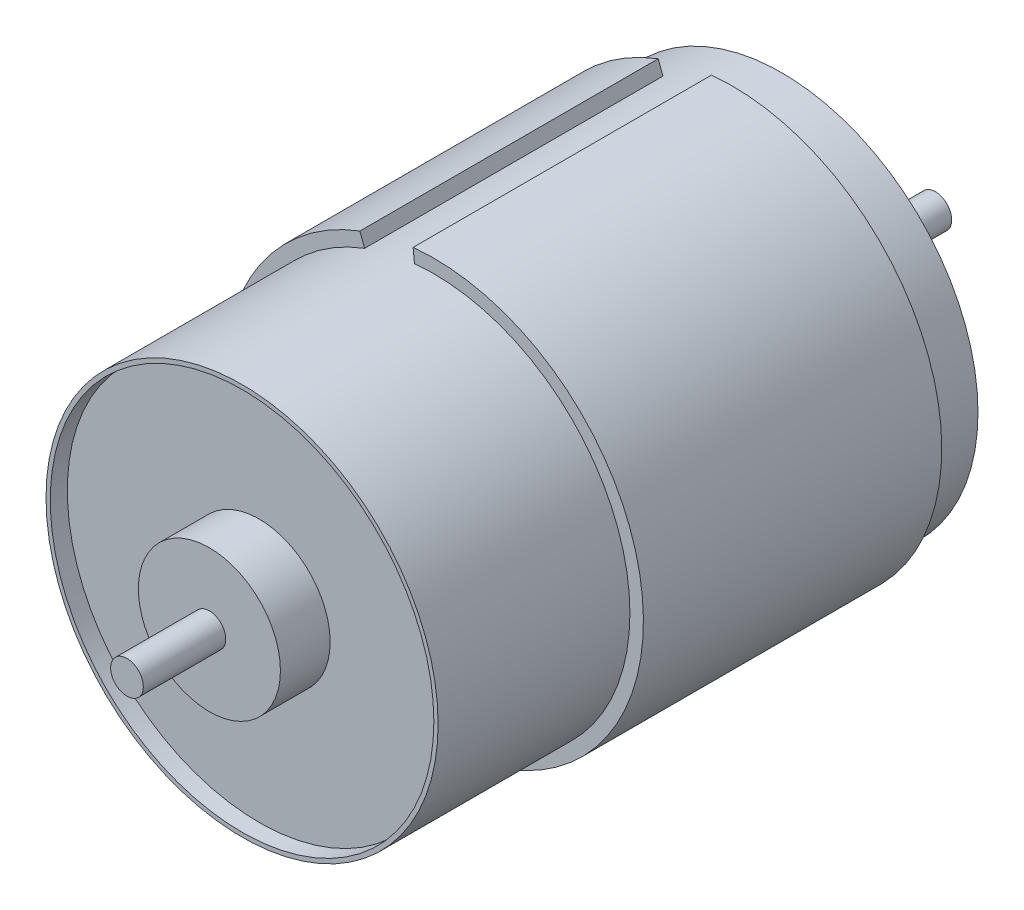
from build123d import *

# Parameters (mm, degrees)
SKETCH1_R           = 13.8
BOSS_EXTRUDE1_DEPTH = 38
BOSS_EXTRUDE2_START = -34.5
BOSS_EXTRUDE2_DEPTH = 21
SKETCH3_R           = 5
BOSS_EXTRUDE3_DEPTH = 2.8
SKETCH4_R           = 13.5
CUT_EXTRUDE1_DEPTH  = 1.2
SKETCH5_R           = 5
BOSS_EXTRUDE4_DEPTH = 3.5
SKETCH6_R           = 1.15
BOSS_EXTRUDE5_DEPTH = 5.8
SKETCH7_R           = 1.15
BOSS_EXTRUDE6_DEPTH = 8
SKETCH8_R           = 1.25
CUT_EXTRUDE2_DEPTH  = 8


with BuildPart() as part:
    # Sketch1 → Boss-Extrude1 (new body)
    with BuildSketch(Plane.XY):
        Circle(SKETCH1_R)
    extrude(amount=BOSS_EXTRUDE1_DEPTH)

    # Sketch2 → Boss-Extrude2 (add)
    with BuildSketch(Plane.XY.offset(38).offset(BOSS_EXTRUDE2_START)):
        with BuildLine():
            Line((-1.458768031, 14.677687006), (-1.36481348, 13.732344453))
            ThreePointArc((-1.36481348, 13.732344453), (3.145567943, -13.436718436), (-4.872500867, 12.911186441))
            Line((-4.872500867, 12.911186441), (-5.207926651, 13.8))
            ThreePointArc((-5.207926651, 13.8), (3.362110664, -14.361709922), (-1.458768031, 14.677687006))
        make_face()
    extrude(amount=BOSS_EXTRUDE2_DEPTH)

    # Sketch3 → Boss-Extrude3 (add)
    with BuildSketch(Plane(origin=(0, 0, 0), x_dir=(-1, 0, 0), z_dir=(0, 0, -1))):
        Circle(SKETCH3_R)
    extrude(amount=BOSS_EXTRUDE3_DEPTH)

    # Sketch4 → Cut-Extrude1 (cut)
    with BuildSketch(Plane.XY.offset(38)):
        Circle(SKETCH4_R)
    extrude(amount=-CUT_EXTRUDE1_DEPTH, mode=Mode.SUBTRACT)

    # Sketch5 → Boss-Extrude4 (add)
    with BuildSketch(Plane.XY.offset(36.8)):
        Circle(SKETCH5_R)
    extrude(amount=BOSS_EXTRUDE4_DEPTH)

    # Sketch6 → Boss-Extrude5 (add)
    with BuildSketch(Plane.XY.offset(40.3)):
        Circle(SKETCH6_R)
    extrude(amount=BOSS_EXTRUDE5_DEPTH)

    # Sketch7 → Boss-Extrude6 (add)
    with BuildSketch(Plane(origin=(0, 0, -2.8), x_dir=(-1, 0, 0), z_dir=(0, 0, -1))):
        Circle(SKETCH7_R)
    extrude(amount=BOSS_EXTRUDE6_DEPTH)

    # Sketch8 → Cut-Extrude2 (cut)
    with BuildSketch(Plane(origin=(0, 0, 0), x_dir=(-1, 0, 0), z_dir=(0, 0, -1))):
        with Locations((-7.789401992, 1.823517648)):
            Circle(SKETCH8_R)
        with Locations((7.789401992, -1.823517648)):
            Circle(SKETCH8_R)
    extrude(amount=-CUT_EXTRUDE2_DEPTH, mode=Mode.SUBTRACT)


solid = part.part
